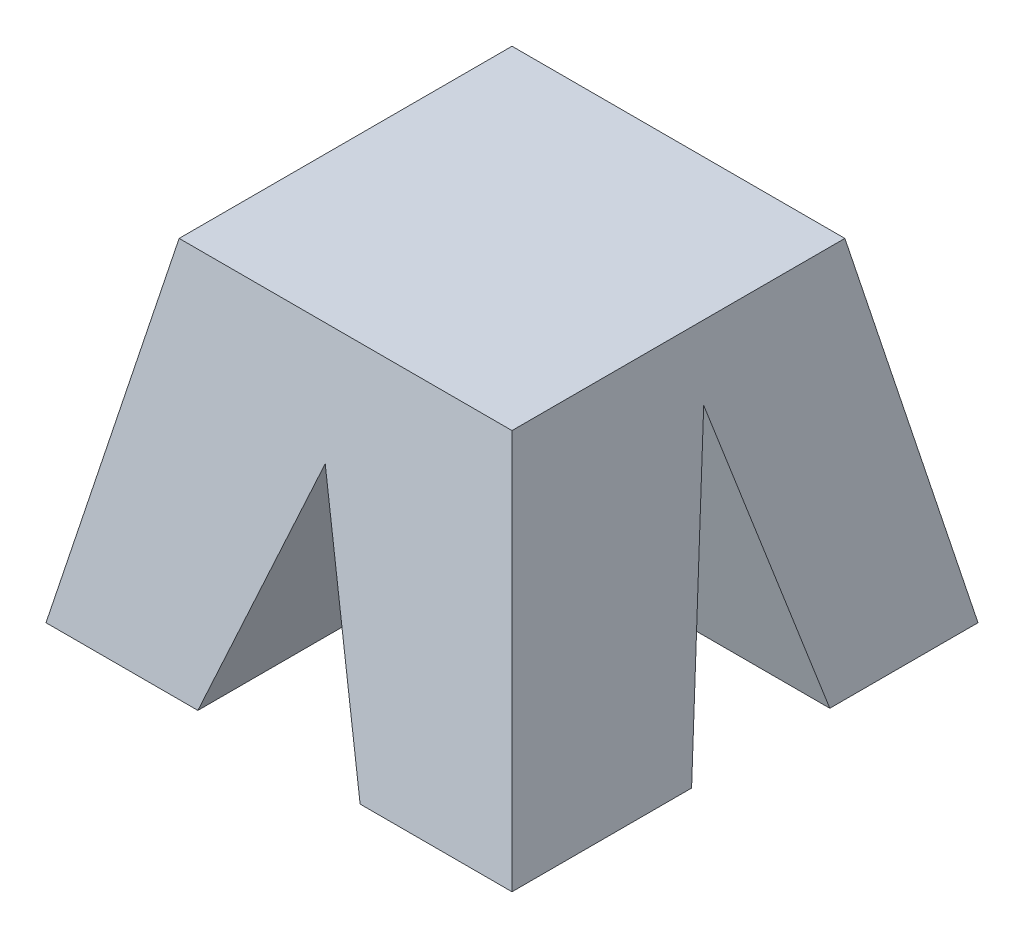
from build123d import *

# Parameters (mm, degrees)
SKETCH2_W          = 2
SKETCH2_H          = 2
SKETCH3_W          = 2.8
SKETCH3_H          = 2.8
CUT_EXTRUDE1_START = -3.2
CUT_EXTRUDE1_DEPTH = 2.8
CUT_EXTRUDE2_START = -3.4
CUT_EXTRUDE2_DEPTH = 2.8


with BuildPart() as part:
    # Sketch2 → Loft1 section 0
    with BuildSketch(Plane.XZ.offset(3)):
        with Locations((0, 1)):
            Rectangle(SKETCH2_W, SKETCH2_H)
    # Sketch3 → Loft1 section 1
    with BuildSketch(Plane(origin=(0, -5, 0), x_dir=(-1, 0, 0), z_dir=(0, -1, 0))):
        with Locations((0, -1)):
            Rectangle(SKETCH3_W, SKETCH3_H)
    loft()

    # Sketch7 → Cut-Extrude1 (cut)
    with BuildSketch(Plane(origin=(1.8, 0, 0), x_dir=(0, 0, -1), z_dir=(1, 0, 0)).offset(CUT_EXTRUDE1_START)):
        Polygon((-0.395154694, -5.358903747), (-0.922322496, -3.37054148), (-1.444019859, -5.50302185), align=None)
    extrude(amount=CUT_EXTRUDE1_DEPTH, mode=Mode.SUBTRACT)

    # Sketch4 → Cut-Extrude2 (cut)
    with BuildSketch(Plane.XY.offset(3).offset(CUT_EXTRUDE2_START)):
        Polygon((0, -3.611513086), (-0.5, -5.035852242), (0.5, -5.035852242), align=None)
    extrude(amount=CUT_EXTRUDE2_DEPTH, mode=Mode.SUBTRACT)


solid = part.part
